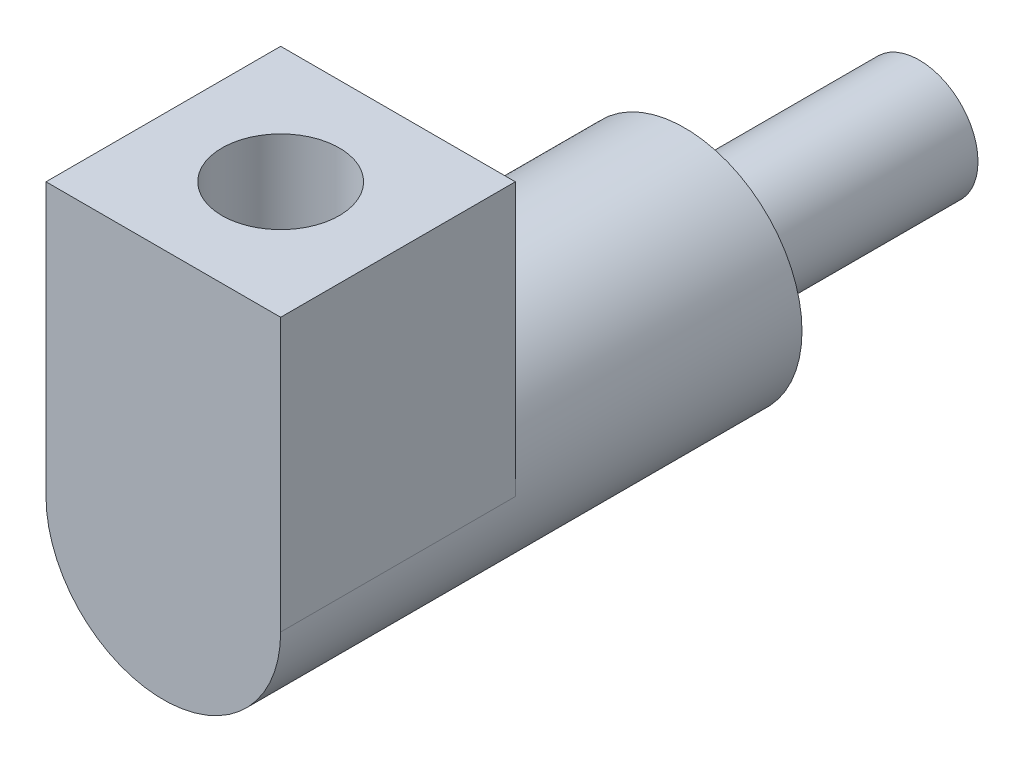
from build123d import *

# Parameters (mm, degrees)
SKETCH1_LINK4_R     = 15
BOSS_EXTRUDE1_DEPTH = 30
SKETCH2_LINK4_R     = 30
BOSS_EXTRUDE2_DEPTH = 73.3
BOSS_EXTRUDE3_DEPTH = 60
SKETCH4_LINK4_R     = 15
CUT_EXTRUDE1_DEPTH  = 30


with BuildPart() as part:
    # sketch1_link4 → Boss-Extrude1 (new body, symmetric)
    with BuildSketch(Plane.XY):
        Circle(SKETCH1_LINK4_R)
    extrude(amount=BOSS_EXTRUDE1_DEPTH, both=True)

    # sketch2_link4 → Boss-Extrude2 (add)
    with BuildSketch(Plane.XY.offset(30)):
        Circle(SKETCH2_LINK4_R)
    extrude(amount=BOSS_EXTRUDE2_DEPTH)

    # sketch3_link4 → Boss-Extrude3 (add)
    with BuildSketch(Plane.XY.offset(103.3)):
        with BuildLine():
            Line((-30, 0), (-30, 69.7))
            Line((-30, 69.7), (30, 69.7))
            Line((30, 69.7), (30, 0))
            ThreePointArc((30, 0), (0, -30), (-30, 0))
        make_face()
    extrude(amount=BOSS_EXTRUDE3_DEPTH)

    # sketch4_link4 → Cut-Extrude1 (cut)
    with BuildSketch(Plane(origin=(0, 69.7, 0), x_dir=(1, 0, 0), z_dir=(0, 1, 0))):
        with Locations((0, -133.3)):
            Circle(SKETCH4_LINK4_R)
    extrude(amount=-CUT_EXTRUDE1_DEPTH, mode=Mode.SUBTRACT)


solid = part.part
